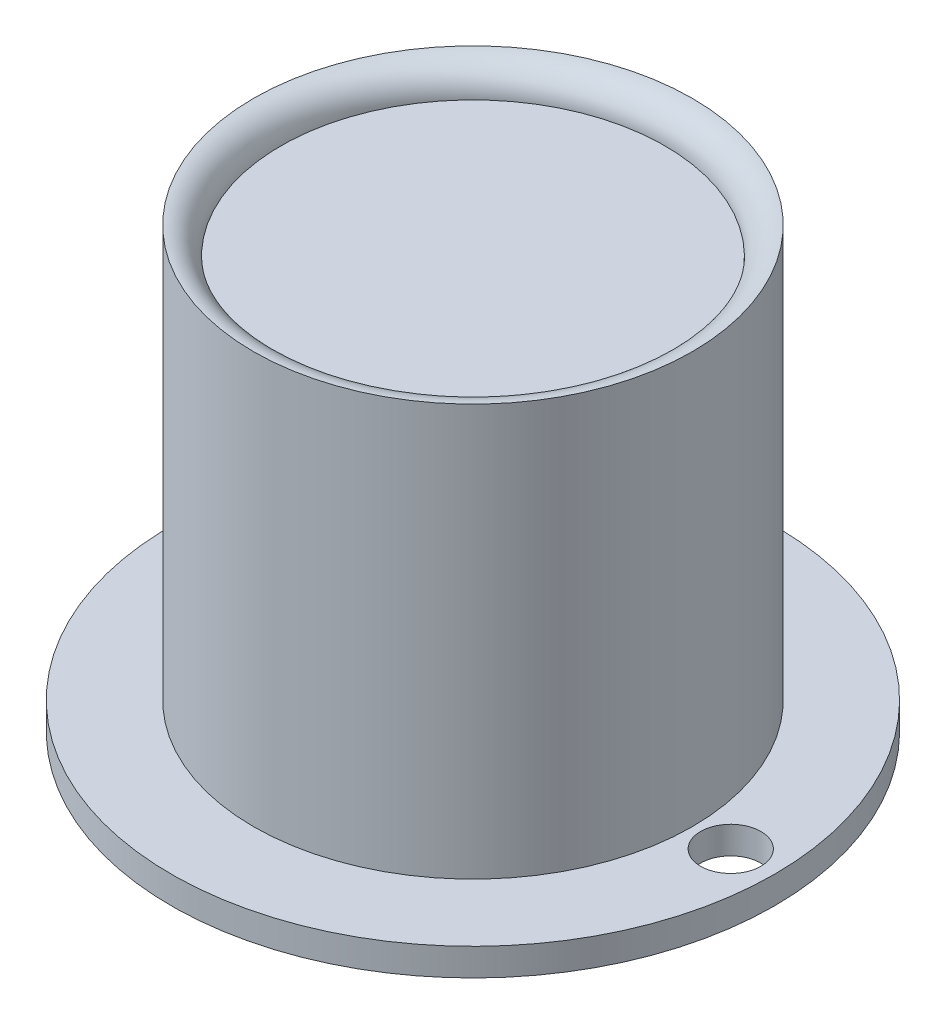
from build123d import *

# Parameters (mm, degrees)
SKETCH_2_R          = 7
CUT_EXTRUDE_1_DEPTH = 10
SKETCH_3_R          = 11
SKETCH_3_R_2        = 7
EXTRUDE_1_DEPTH     = 1
SKETCH_4_R          = 1.1
CUT_EXTRUDE_2_DEPTH = 1


with BuildPart() as part:
    # 草图1 → 旋转1 (revolve)
    with BuildSketch(Plane.XY):
        with BuildLine():
            Line((0, 14), (-7, 14))
            ThreePointArc((-7, 14), (-7.292893219, 14.707106781), (-8, 15))
            Line((-8, 15), (-8, 0))
            Line((-8, 0), (0, 0))
            Line((0, 0), (0, 14))
        make_face()
    revolve(axis=Axis((0, 0, 0), (0, 1, 0)))

    # 草图2 → 切除-拉伸1 (cut)
    with BuildSketch(Plane.XZ):
        Circle(SKETCH_2_R)
    extrude(amount=-CUT_EXTRUDE_1_DEPTH, mode=Mode.SUBTRACT)

    # 草图3 → 凸台-拉伸1 (add)
    with BuildSketch(Plane.XZ):
        Circle(SKETCH_3_R)
        Circle(SKETCH_3_R_2, mode=Mode.SUBTRACT)
    extrude(amount=EXTRUDE_1_DEPTH)

    # 草图4 → 切除-拉伸2 (cut)
    with BuildSketch(Plane.XZ.offset(1)):
        with Locations((9.4, 0)):
            Circle(SKETCH_4_R)
        with Locations((-9.4, 0)):
            Circle(SKETCH_4_R)
    extrude(amount=-CUT_EXTRUDE_2_DEPTH, mode=Mode.SUBTRACT)


solid = part.part
